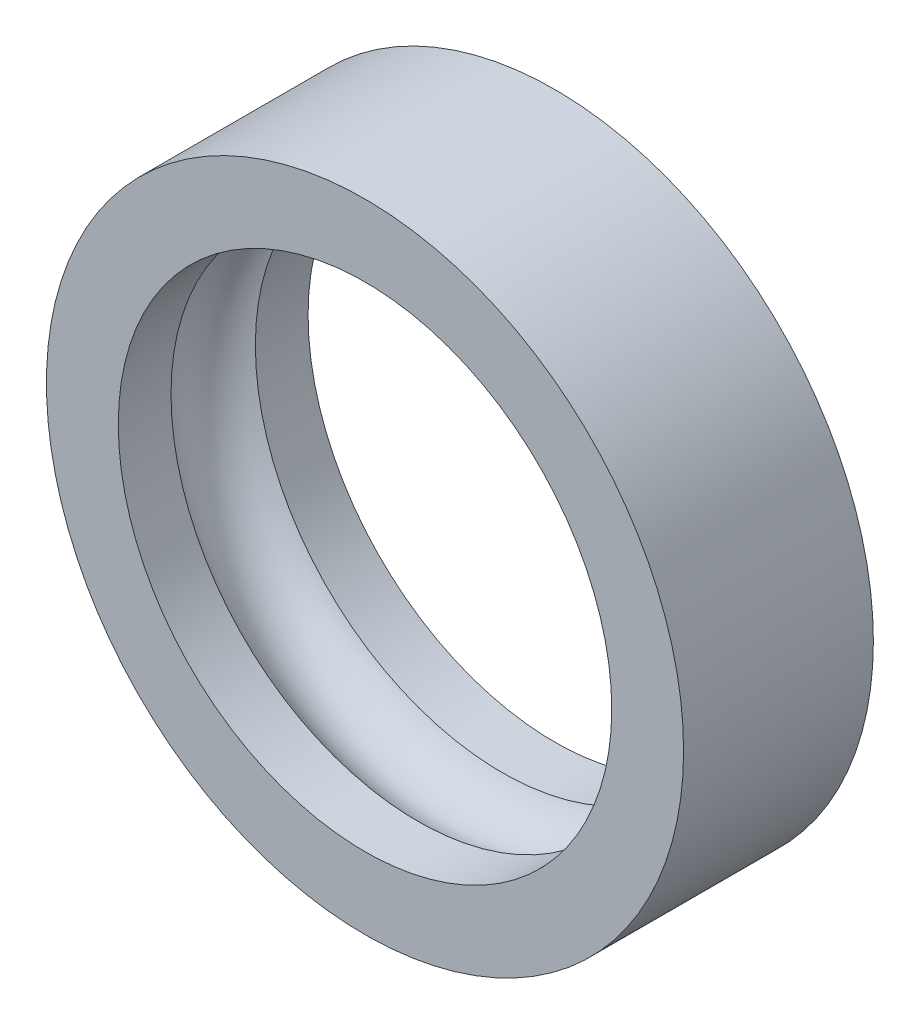
from build123d import *


with BuildPart() as part:
    # Sketch1 → Revolve1 (revolve)
    with BuildSketch(Plane(origin=(0, 0, 0), x_dir=(0, 0, -1), z_dir=(1, 0, 0))):
        with BuildLine():
            Line((6.3, 23.5), (-6.3, 23.5))
            Line((-6.3, 23.5), (-7, 23.5))
            Line((-7, 23.5), (-7, 22.8))
            Line((-7, 22.8), (-7, 18.200549451))
            Line((-7, 18.200549451), (-3.111111111, 18.200549451))
            ThreePointArc((-3.111111111, 18.200549451), (0, 20.182652918), (3.111111111, 18.200549451))
            Line((3.111111111, 18.200549451), (7, 18.200549451))
            Line((7, 18.200549451), (7, 22.8))
            Line((7, 22.8), (7, 23.5))
            Line((7, 23.5), (6.3, 23.5))
        make_face()
    revolve(axis=Axis((0, 0, 7), (0, 0, -1)))


solid = part.part
